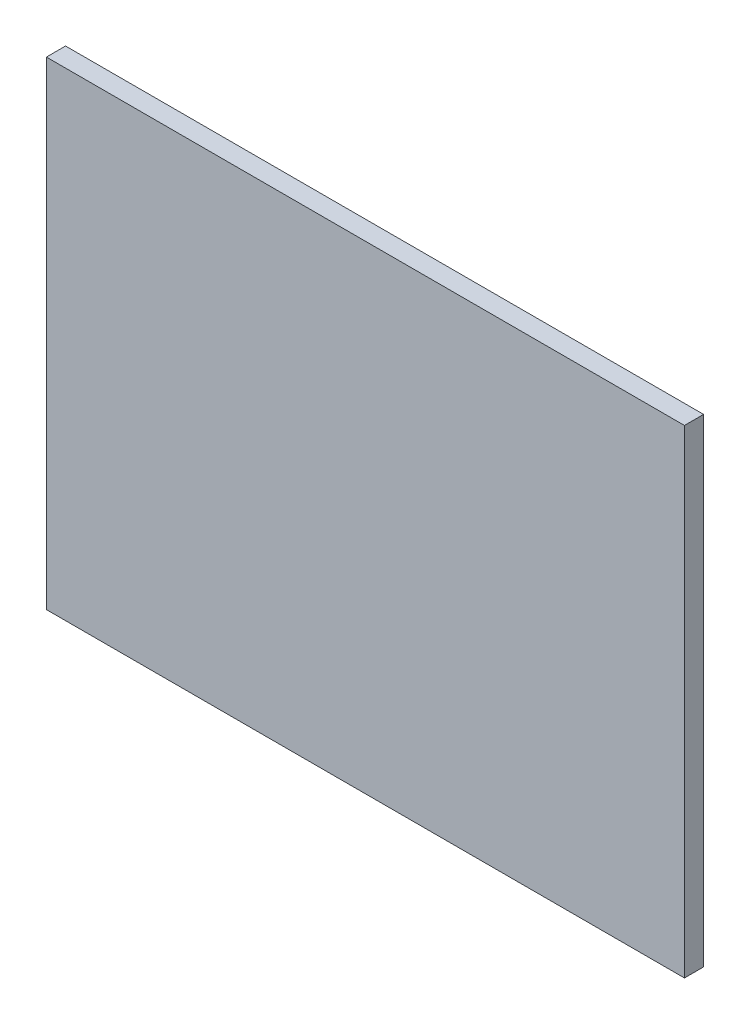
from build123d import *

# Parameters (mm, degrees)
CROQUIS1_W              = 100
CROQUIS1_H              = 75
SALIENTE_EXTRUIR1_DEPTH = 3


with BuildPart() as part:
    # Croquis1 → Saliente-Extruir1 (new body)
    with BuildSketch(Plane.XY):
        Rectangle(CROQUIS1_W, CROQUIS1_H)
    extrude(amount=SALIENTE_EXTRUIR1_DEPTH)


solid = part.part
